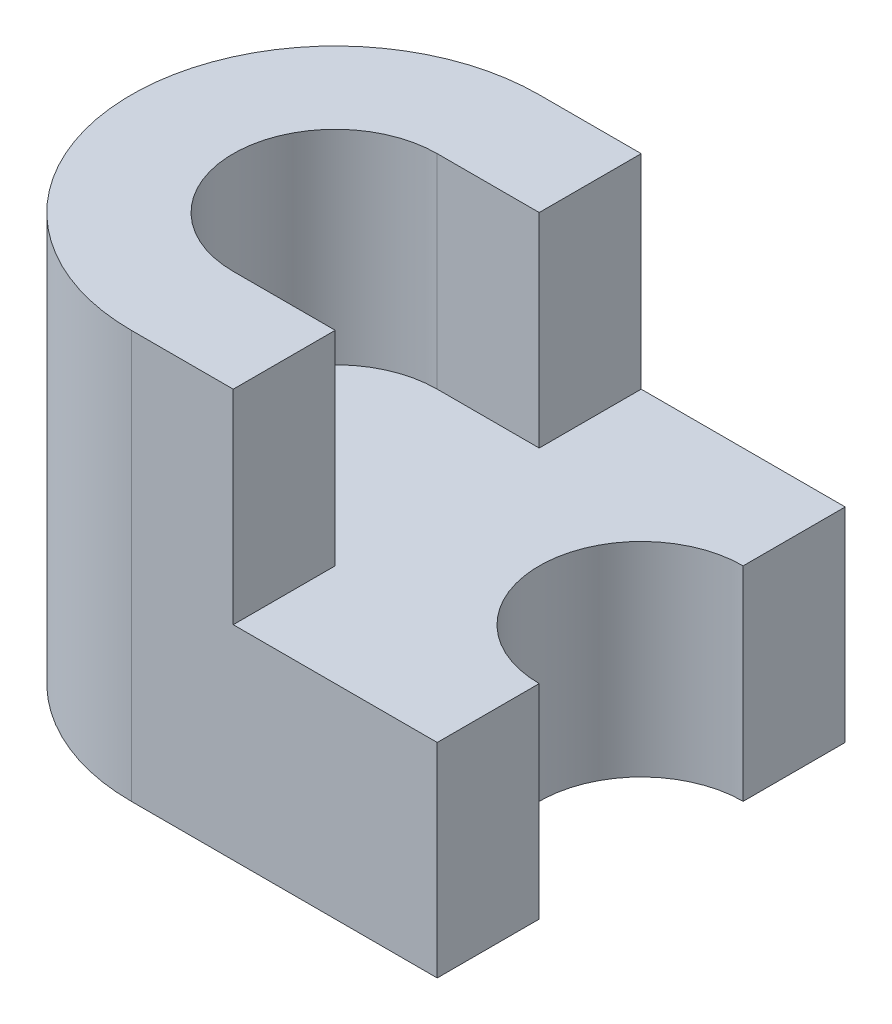
from build123d import *

# Parameters (mm, degrees)
EXTRUDE_1_DEPTH = 10
EXTRUDE_2_DEPTH = 20


with BuildPart() as part:
    # 草圖1 → 填料-伸長1 (new body)
    with BuildSketch(Plane(origin=(0, 0, 0), x_dir=(1, 0, 0), z_dir=(0, 1, 0))):
        with BuildLine():
            Line((15, 10), (0, 10))
            ThreePointArc((0, 10), (-10, 0), (0, -10))
            Line((0, -10), (15, -10))
            Line((15, -10), (15, -5))
            ThreePointArc((15, -5), (10, 0), (15, 5))
            Line((15, 5), (15, 10))
        make_face()
    extrude(amount=EXTRUDE_1_DEPTH)

    # 草圖1<3> → 填料-伸長2 (add)
    with BuildSketch(Plane(origin=(0, 0, 0), x_dir=(1, 0, 0), z_dir=(0, 1, 0))):
        with BuildLine():
            Line((5, 5), (5, 10))
            Line((5, 10), (0, 10))
            ThreePointArc((0, 10), (-10, 0), (0, -10))
            Line((0, -10), (5, -10))
            Line((5, -10), (5, -5))
            Line((5, -5), (0, -5))
            ThreePointArc((0, -5), (-5, 0), (0, 5))
            Line((0, 5), (5, 5))
        make_face()
    extrude(amount=EXTRUDE_2_DEPTH)


solid = part.part
